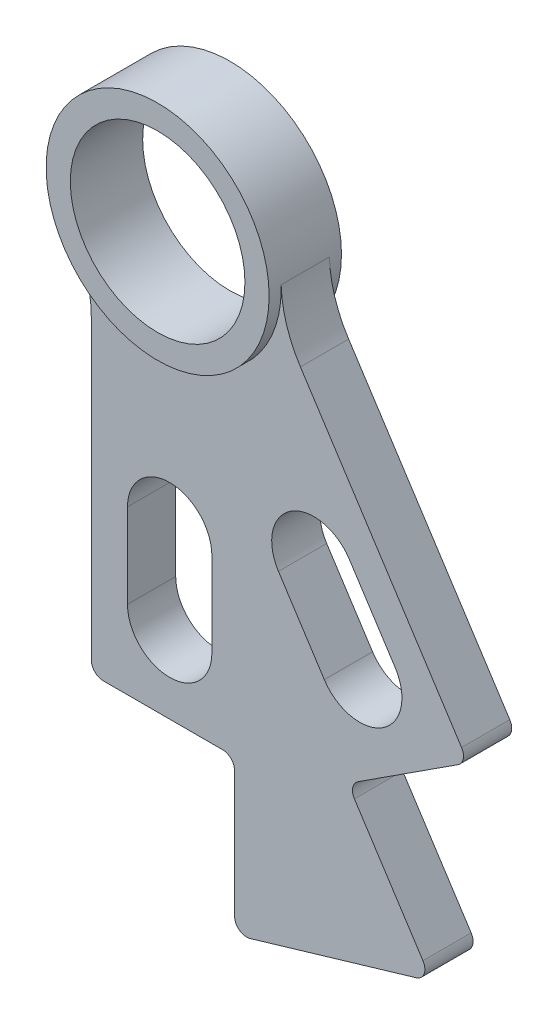
from build123d import *

# Parameters (mm, degrees)
SKETCH1_R           = 11.495405
BOSS_EXTRUDE2_DEPTH = 4.7625
BOSS_EXTRUDE3_DEPTH = 3.175
FILLET1_R           = 1.5875


with BuildPart() as part:
    # Sketch1 → Boss-Extrude2 (new, symmetric)
    with BuildSketch(Plane.XY):
        with BuildLine():
            ThreePointArc((14.672983865, 0.491098707), (-4.158599684, 14.079903484), (-12.585193267, -7.559797873))
            ThreePointArc((-12.585193267, -7.559797873), (4.158599684, -14.079903484), (14.672983865, 0.491098707))
        make_face()
        Circle(SKETCH1_R, mode=Mode.SUBTRACT)
    extrude(amount=BOSS_EXTRUDE2_DEPTH, both=True)

    # Sketch1_4 → Boss-Extrude3 (add, symmetric)
    with BuildSketch(Plane.XY):
        with BuildLine():
            ThreePointArc((-12.585193267, -7.559797873), (-10.89585042, -11.492870345), (-10.31875, -15.734319794))
            Line((-10.31875, -15.734319794), (-10.31875, -56.374319794))
            Line((-10.31875, -56.374319794), (8.54075, -56.374319794))
            Line((8.54075, -56.374319794), (8.54075, -76.694319794))
            Line((8.54075, -76.694319794), (34.499171822, -69.027315193))
            Line((34.499171822, -69.027315193), (23.458960581, -51.968120144))
            Line((23.458960581, -51.968120144), (39.292025986, -41.721424085))
            Line((39.292025986, -41.721424085), (17.211603503, -7.603033986))
            ThreePointArc((17.211603503, -7.603033986), (15.391641433, -3.728672569), (14.672983865, 0.491098707))
            ThreePointArc((14.672983865, 0.491098707), (4.158599684, -14.079903484), (-12.585193267, -7.559797873))
        make_face()
        with BuildLine():
            ThreePointArc((5.55625, -46.055569794), (0, -51.611819794), (-5.55625, -46.055569794))
            Line((-5.55625, -46.055569794), (-5.55625, -34.943069794))
            ThreePointArc((-5.55625, -34.943069794), (0, -29.386819794), (5.55625, -34.943069794))
            Line((5.55625, -34.943069794), (5.55625, -46.055569794))
        make_face(mode=Mode.SUBTRACT)
        with BuildLine():
            ThreePointArc((29.687419875, -35.646101109), (28.04160399, -43.329532516), (20.358172583, -41.683716631))
            Line((20.358172583, -41.683716631), (14.32055706, -32.354469339))
            ThreePointArc((14.32055706, -32.354469339), (15.966372945, -24.671037931), (23.649804353, -26.316853816))
            Line((23.649804353, -26.316853816), (29.687419875, -35.646101109))
        make_face(mode=Mode.SUBTRACT)
    extrude(amount=BOSS_EXTRUDE3_DEPTH, both=True)

    # Fillet1
    fillet1_edges = [part.edges().sort_by_distance(p)[0] for p in [
        (-10.31875, -56.374319794, 0),
        (39.292025986, -41.721424085, 0),
        (8.54075, -76.694319794, 0),
        (34.499171822, -69.027315193, 0),
        (23.458960581, -51.968120144, 0),
        (8.54075, -56.374319794, 0),
    ]]
    fillet(fillet1_edges, radius=FILLET1_R)


solid = part.part
